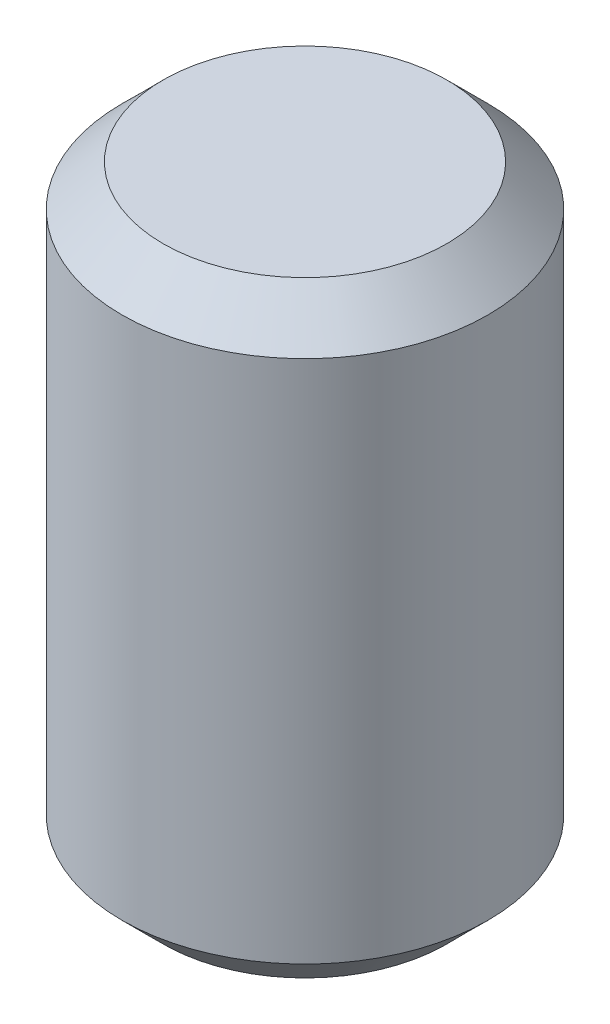
from build123d import *

# Parameters (mm, degrees)
SKETCH1_W          = 0.89
SKETCH1_H          = 2.95
CUT_EXTRUDE1_DEPTH = 0.375
CHAMFER1_SIZE      = 0.2


with BuildPart() as part:
    # Sketch1 → Revolve1 (revolve)
    with BuildSketch(Plane(origin=(0, 0, 0), x_dir=(-1, 0, 0), z_dir=(0, 0, -1))):
        with Locations((-0.445, 1.475)):
            Rectangle(SKETCH1_W, SKETCH1_H)
    revolve(axis=Axis((0, 0, 0), (0, 1, 0)))

    # Sketch2 → Cut-Extrude1 (cut)
    with BuildSketch(Plane.XZ):
        Polygon((-0.235, 0.40703194), (-0.47, 0), (-0.235, -0.40703194), (0.235, -0.40703194), (0.47, 0), (0.235, 0.40703194), align=None)
    extrude(amount=-CUT_EXTRUDE1_DEPTH, mode=Mode.SUBTRACT)

    # Chamfer1
    chamfer1_edges = [part.edges().sort_by_distance(p)[0] for p in [
        (-0.89, 2.95, 0),
        (-0.89, 0, 0),
    ]]
    chamfer(chamfer1_edges, length=CHAMFER1_SIZE)


solid = part.part
